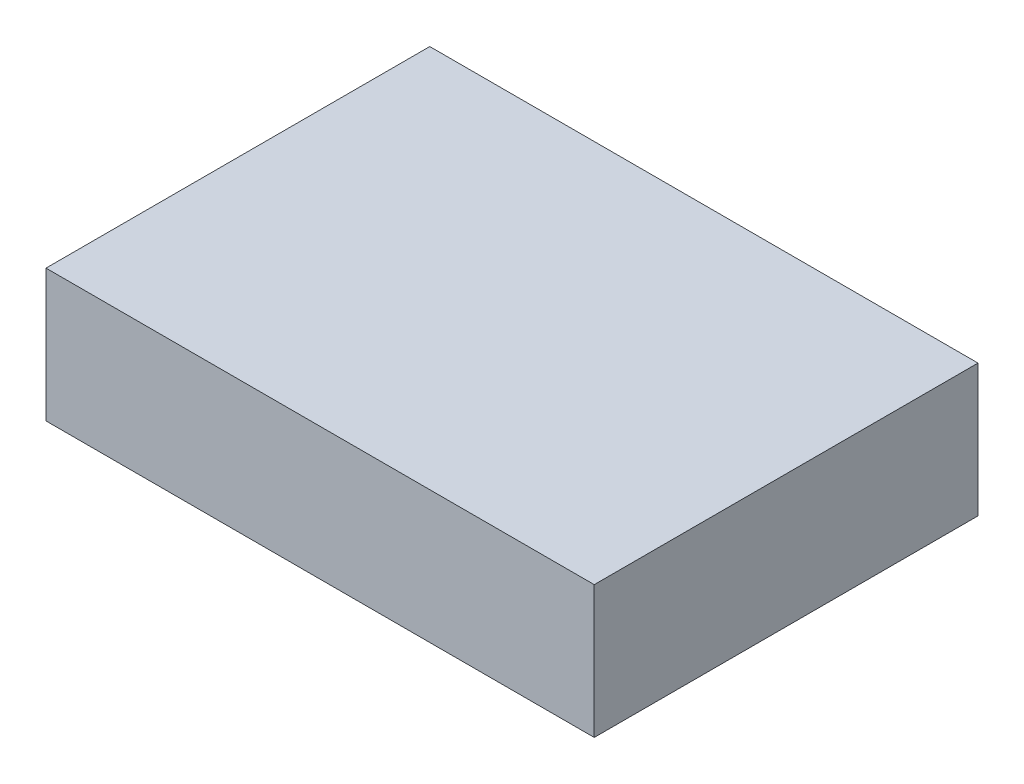
from build123d import *

# Parameters (mm, degrees)
SKETCH1_W           = 14
SKETCH1_H           = 3.38
BOSS_EXTRUDE1_DEPTH = 9.8
BOSS_EXTRUDE2_DEPTH = 0.0001


with BuildPart() as part:
    # Sketch1 → Boss-Extrude1 (new body)
    with BuildSketch(Plane.XY):
        Rectangle(SKETCH1_W, SKETCH1_H)
    extrude(amount=BOSS_EXTRUDE1_DEPTH)

    # Sketch2 → Boss-Extrude2 (add)
    with BuildSketch(Plane.XZ.offset(1.69)):
        Polygon((-4.313461538, 4.9), (-3.894325921, 8.075), (-3.853620793, 8.075), (-2.542788462, 5.469871795), (-1.235136218, 8.075), (-1.193795072, 8.075), (-0.772115385, 4.9), (-1.058323317, 4.9), (-1.362339744, 7.184575321), (-2.50844351, 4.9), (-2.57268129, 4.9), (-3.723237179, 7.189663462), (-4.026617588, 4.9), align=None)
        Polygon((-0.120833333, 8.075), (0.164102564, 8.075), (0.164102564, 5.225641026), (1.38525641, 5.225641026), (1.38525641, 4.9), (-0.120833333, 4.9), align=None)
        with BuildLine():
            Line((2.036538462, 7.098076923), (1.751602564, 7.098076923))
            add(Edge.make_bspline(
                [(1.751602564, 7.098076923), (1.753459624, 7.135878371), (1.757106841, 7.210119409), (1.774186789, 7.318363239), (1.798626014, 7.421827235), (1.833180404, 7.519680657), (1.876093956, 7.612788718), (1.927556195, 7.700781589), (1.988510617, 7.783323596), (2.057641011, 7.859649547), (2.132723991, 7.9296697), (2.213737236, 7.990135528), (2.298868082, 8.041223701), (2.387858251, 8.083933113), (2.481711762, 8.115991402), (2.579576926, 8.139778175), (2.681883714, 8.154089574), (2.751588592, 8.155627894), (2.787039263, 8.156410256)],
                knots=[0, 0, 0, 0, 0.000113468, 0.000222848, 0.000328209, 0.000432002, 0.000533594, 0.000635367, 0.000737261, 0.00084084, 0.000943908, 0.001044781, 0.001143495, 0.001241361, 0.001340322, 0.001440438, 0.001543158, 0.001649467, 0.001649467, 0.001649467, 0.001649467], degree=3))
            add(Edge.make_bspline(
                [(2.787039263, 8.156410256), (2.821853659, 8.155595228), (2.890262703, 8.153993726), (2.990104673, 8.140240507), (3.085152647, 8.118699863), (3.175220835, 8.088478021), (3.259590623, 8.047852148), (3.338895813, 7.999050095), (3.414080548, 7.942607819), (3.481759559, 7.876156146), (3.543906174, 7.805215411), (3.597520363, 7.729479956), (3.643433732, 7.651257675), (3.681703985, 7.569952092), (3.709876339, 7.484797659), (3.731265142, 7.397034125), (3.743355011, 7.305753047), (3.745210502, 7.243970671), (3.746153846, 7.212560096)],
                knots=[0, 0, 0, 0, 0.000104402, 0.000205146, 0.000301729, 0.000396461, 0.000489487, 0.000581988, 0.000675485, 0.000770845, 0.000865978, 0.000958102, 0.001048749, 0.001137814, 0.001227115, 0.00131736, 0.00140848, 0.001502716, 0.001502716, 0.001502716, 0.001502716], degree=3))
            add(Edge.make_bspline(
                [(3.746153846, 7.212560096), (3.744617815, 7.168338846), (3.741572707, 7.080672367), (3.715524666, 6.951844598), (3.674842474, 6.827027711), (3.625859157, 6.726573158), (3.576444868, 6.645625632), (3.531915487, 6.578979021), (3.479786694, 6.50721906), (3.419299771, 6.430586047), (3.351705951, 6.348479726), (3.276392988, 6.260949697), (3.19282383, 6.168900306), (3.134169333, 6.106030225), (3.103776042, 6.073452524)],
                knots=[0, 0, 0, 0, 0.00013255, 0.000262774, 0.000392702, 0.000525544, 0.00059688, 0.000677142, 0.000765941, 0.000862892, 0.000969979, 0.001084979, 0.001209264, 0.001342927, 0.001342927, 0.001342927, 0.001342927], degree=3))
            Line((3.103776042, 6.073452524), (2.309390024, 5.225641026))
            Line((2.309390024, 5.225641026), (3.786858974, 5.225641026))
            Line((3.786858974, 5.225641026), (3.786858974, 4.9))
            Line((3.786858974, 4.9), (1.629487179, 4.9))
            Line((1.629487179, 4.9), (2.860817308, 6.21401242))
            add(Edge.make_bspline(
                [(2.860817308, 6.21401242), (2.890796462, 6.245307312), (2.948380282, 6.305418396), (3.029825906, 6.393178081), (3.102976988, 6.474593736), (3.168307051, 6.549511533), (3.224398874, 6.619027313), (3.274175827, 6.680889651), (3.314058899, 6.737816902), (3.35734358, 6.803803031), (3.399266263, 6.88436849), (3.435291043, 6.982824051), (3.45725737, 7.08417663), (3.45989247, 7.152667764), (3.461217949, 7.187119391)],
                knots=[0, 0, 0, 0, 0.000130011, 0.000249724, 0.000359165, 0.000458368, 0.000547868, 0.000627136, 0.000696488, 0.000756294, 0.000863824, 0.000968046, 0.001070082, 0.001173354, 0.001173354, 0.001173354, 0.001173354], degree=3))
            add(Edge.make_bspline(
                [(3.461217949, 7.187119391), (3.46064124, 7.208783231), (3.459504657, 7.2514785), (3.449473745, 7.314076581), (3.434314929, 7.374460376), (3.412593159, 7.432815624), (3.383921331, 7.488555608), (3.349020479, 7.541748179), (3.30875235, 7.593173169), (3.262169413, 7.641390804), (3.210996106, 7.685551612), (3.156935608, 7.724671318), (3.099740156, 7.75736394), (3.039650903, 7.784164112), (2.97683537, 7.805187494), (2.911172065, 7.819754919), (2.842842422, 7.828901173), (2.796184893, 7.830138671), (2.772410857, 7.830769231)],
                knots=[0, 0, 0, 0, 6.4952e-05, 0.000128007, 0.000189711, 0.000251496, 0.000314359, 0.000377338, 0.000442102, 0.000510025, 0.000578115, 0.000644657, 0.000709898, 0.00077538, 0.000841751, 0.000908254, 0.000976888, 0.001048193, 0.001048193, 0.001048193, 0.001048193], degree=3))
            add(Edge.make_bspline(
                [(2.772410857, 7.830769231), (2.747581602, 7.830120594), (2.698821044, 7.82884678), (2.627230207, 7.81993622), (2.558935252, 7.804563922), (2.493764382, 7.783539367), (2.43160733, 7.756816255), (2.372766375, 7.723531601), (2.317373612, 7.683813718), (2.265324908, 7.638782642), (2.217369727, 7.588647032), (2.175235776, 7.532757994), (2.138420277, 7.472135982), (2.106299044, 7.406944568), (2.080213525, 7.336592211), (2.060280738, 7.26132865), (2.044508385, 7.181480682), (2.039239227, 7.126339927), (2.036538462, 7.098076923)],
                knots=[0, 0, 0, 0, 7.4482e-05, 0.00014627, 0.000216015, 0.0002842, 0.000351428, 0.000418642, 0.000486589, 0.000555575, 0.000624857, 0.000694312, 0.000765104, 0.000837353, 0.000912017, 0.000989777, 0.001070732, 0.001155858, 0.001155858, 0.001155858, 0.001155858], degree=3))
        make_face()
    extrude(amount=BOSS_EXTRUDE2_DEPTH)


solid = part.part
